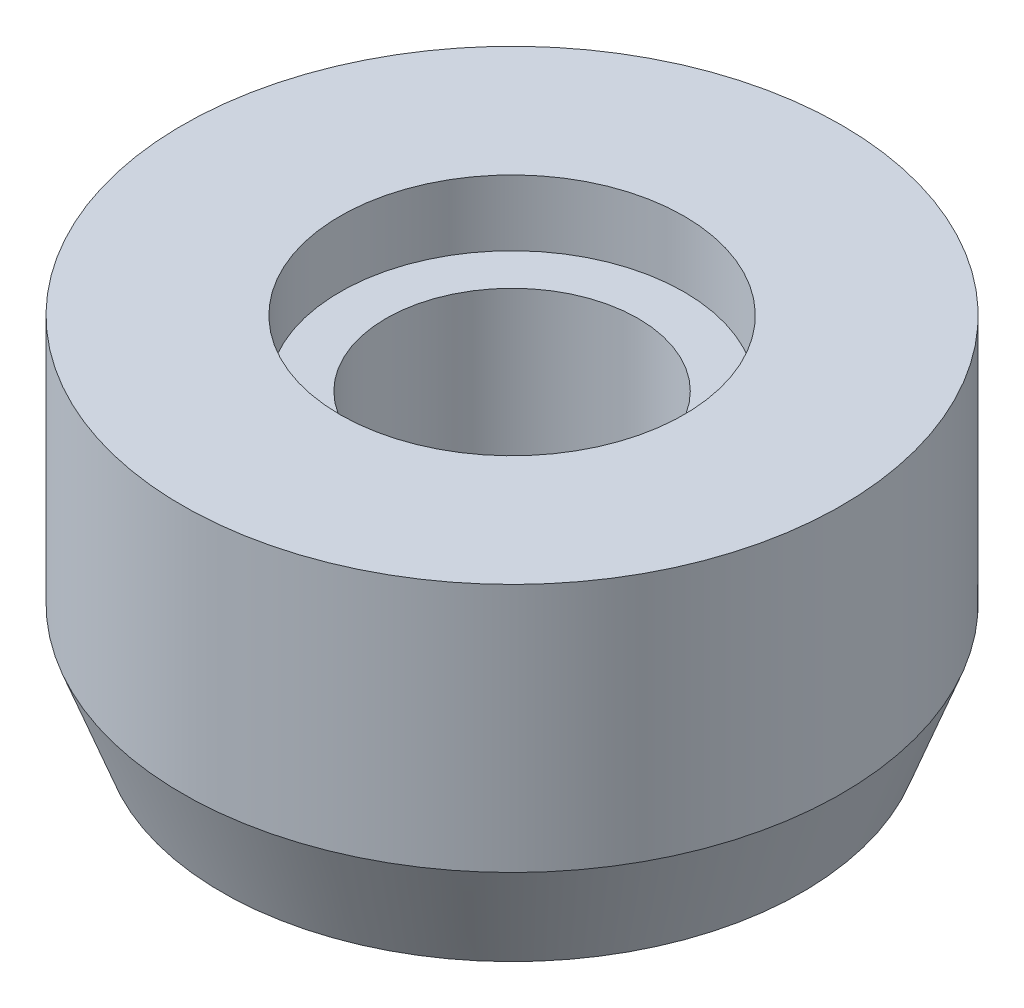
from build123d import *


with BuildPart() as part:
    # Sketch1 → Revolve1 (revolve)
    with BuildSketch(Plane.XY):
        Polygon((4.8, 0), (11.05, 0), (12.55, 4), (12.55, 13.5), (6.55, 13.5), (6.55, 11), (4.8, 11), align=None)
    revolve(axis=Axis((0, 0, 0), (0, 1, 0)))


solid = part.part
